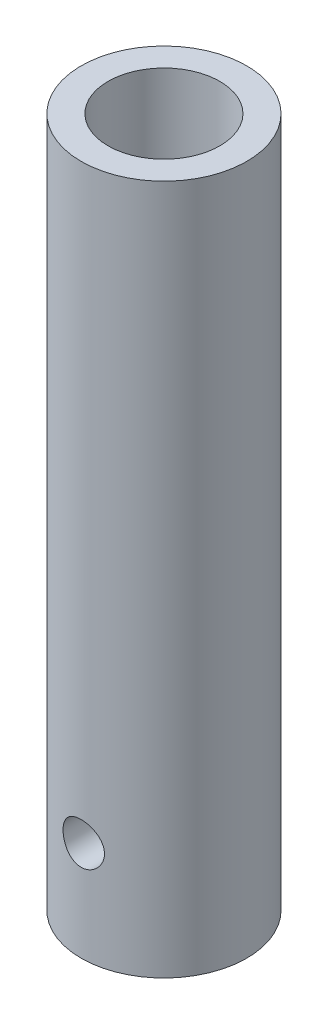
from build123d import *

# Parameters (mm, degrees)
SKETCH1_R               = 6
BOSS_EXTRUDE1_DEPTH     = 50
CUT_EXTRUDE2_START      = 50
SKETCH1_4_R             = 4.05
CUT_EXTRUDE2_DEPTH      = 15
SKETCH3_R               = 1.5
CUT_EXTRUDE3_DEPTH      = 7
CUT_EXTRUDE3_DEPTH_BACK = 7


with BuildPart() as part:
    # Sketch1 → Boss-Extrude1 (new body)
    with BuildSketch(Plane(origin=(0, 0, 0), x_dir=(1, 0, 0), z_dir=(0, 1, 0))):
        Circle(SKETCH1_R)
    extrude(amount=BOSS_EXTRUDE1_DEPTH)

    # Sketch1_4 → Cut-Extrude2 (cut)
    with BuildSketch(Plane(origin=(0, 0, 0), x_dir=(1, 0, 0), z_dir=(0, 1, 0)).offset(CUT_EXTRUDE2_START)):
        Circle(SKETCH1_4_R)
    extrude(amount=-CUT_EXTRUDE2_DEPTH, mode=Mode.SUBTRACT)

    # Sketch3 → Cut-Extrude3 (cut, two sides)
    with BuildSketch(Plane.XY) as cut_extrude3_sk:
        with Locations((0, 7.20619719)):
            Circle(SKETCH3_R)
    extrude(amount=CUT_EXTRUDE3_DEPTH, mode=Mode.SUBTRACT)
    extrude(cut_extrude3_sk.sketch, amount=-CUT_EXTRUDE3_DEPTH_BACK, mode=Mode.SUBTRACT)


solid = part.part
